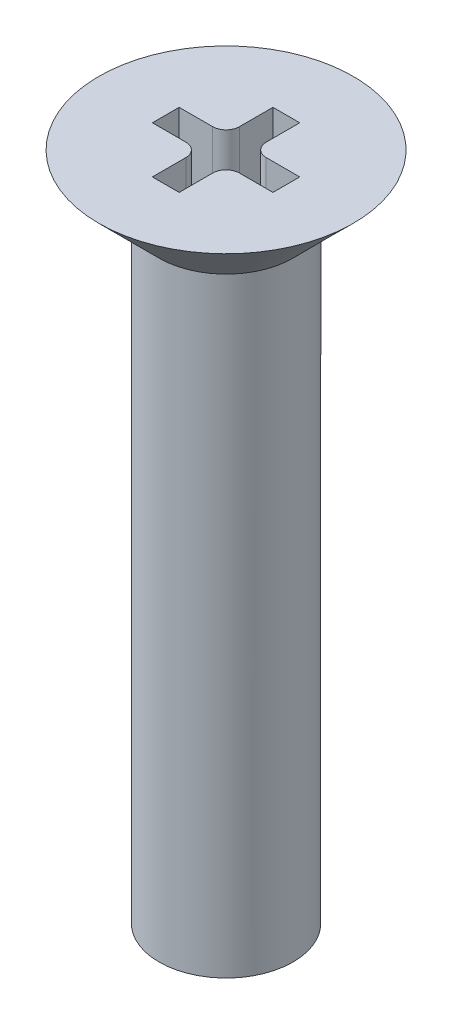
from build123d import *

# Parameters (mm, degrees)
SKETCH2_R           = 1
BOSS_EXTRUDE1_DEPTH = 8.8
CUT_EXTRUDE1_DEPTH  = 1


with BuildPart() as part:
    # Sketch1 → Revolve1 (revolve)
    with BuildSketch(Plane(origin=(0, 0, 0), x_dir=(0, 0, -1), z_dir=(1, 0, 0))):
        Polygon((0, 0), (-1.9, 0), (-1, -0.9), (-1, -1.2), (0, -1.2), align=None)
    revolve(axis=Axis((0, 0.872326939, 0), (0, -1, 0)))

    # Sketch2 → Boss-Extrude1 (add)
    with BuildSketch(Plane.XZ.offset(1.2)):
        Circle(SKETCH2_R)
    extrude(amount=BOSS_EXTRUDE1_DEPTH)

    # Sketch3 → Cut-Extrude1 (cut)
    with BuildSketch(Plane(origin=(0, 0, 0), x_dir=(1, 0, 0), z_dir=(0, 1, 0))):
        with BuildLine():
            Line((-0.9, -0.2), (-0.4, -0.2))
            ThreePointArc((-0.4, -0.2), (-0.258578644, -0.258578644), (-0.2, -0.4))
            Line((-0.2, -0.4), (-0.2, -0.9))
            Line((-0.2, -0.9), (0.2, -0.9))
            Line((0.2, -0.9), (0.2, -0.4))
            ThreePointArc((0.2, -0.4), (0.258578644, -0.258578644), (0.4, -0.2))
            Line((0.4, -0.2), (0.9, -0.2))
            Line((0.9, -0.2), (0.9, 0.2))
            Line((0.9, 0.2), (0.4, 0.2))
            ThreePointArc((0.4, 0.2), (0.258578644, 0.258578644), (0.2, 0.4))
            Line((0.2, 0.4), (0.2, 0.9))
            Line((0.2, 0.9), (-0.2, 0.9))
            Line((-0.2, 0.9), (-0.2, 0.4))
            ThreePointArc((-0.2, 0.4), (-0.258578644, 0.258578644), (-0.4, 0.2))
            Line((-0.4, 0.2), (-0.9, 0.2))
            Line((-0.9, 0.2), (-0.9, -0.2))
        make_face()
    extrude(amount=-CUT_EXTRUDE1_DEPTH, mode=Mode.SUBTRACT)


solid = part.part
